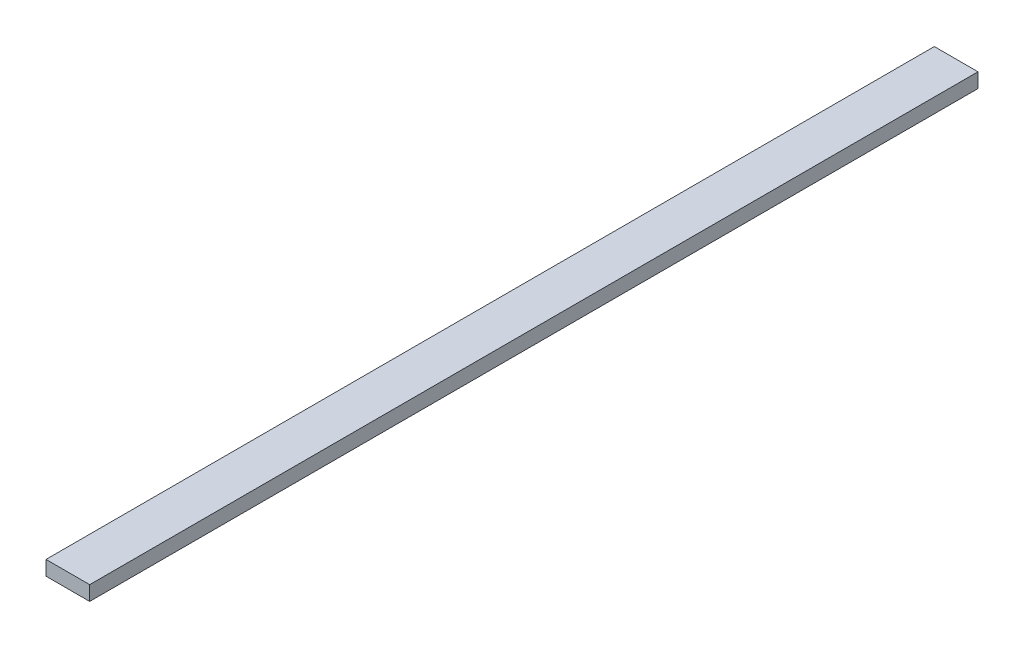
from build123d import *

# Parameters (mm, degrees)
ESBO_O2_W                = 15
ESBO_O2_H                = 5
RESSALTO_EXTRUS_O1_DEPTH = 305


with BuildPart() as part:
    # Esboço2 → Ressalto-extrusão1 (new body)
    with BuildSketch(Plane.XY):
        with Locations((175.5, -6)):
            Rectangle(ESBO_O2_W, ESBO_O2_H)
    extrude(amount=RESSALTO_EXTRUS_O1_DEPTH)


solid = part.part
